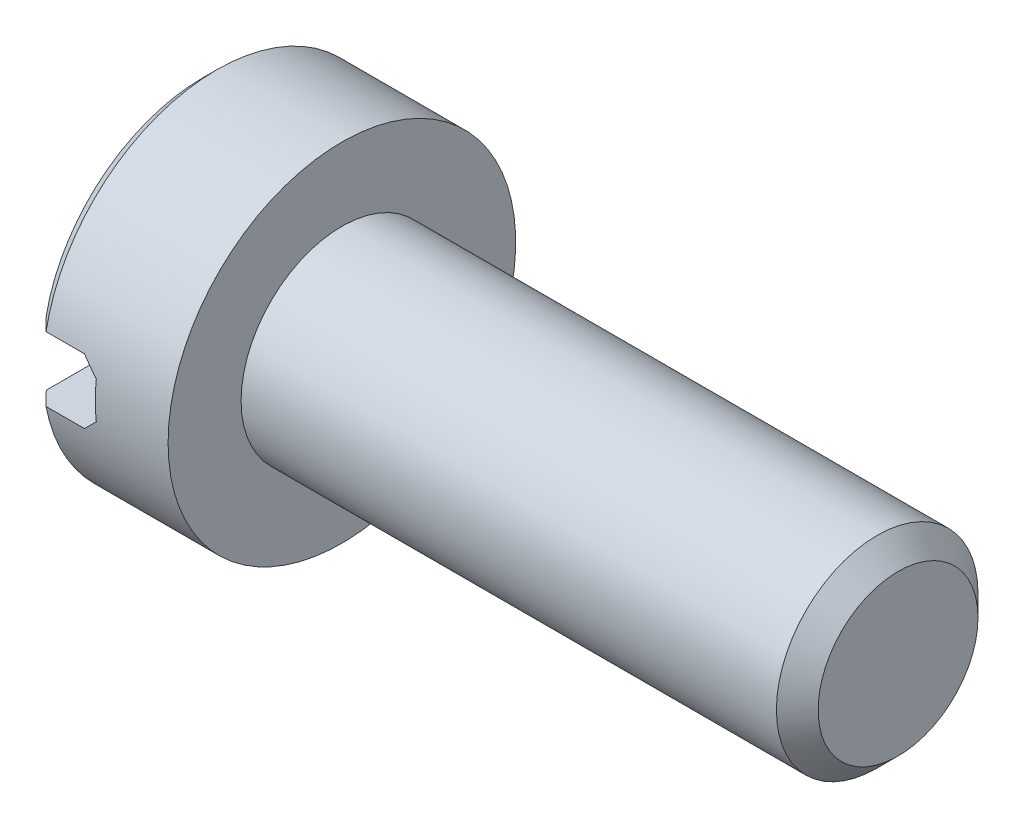
from build123d import *

# Parameters (mm, degrees)
ENL_V_MAT_EXTRU_1_DEPTH = 5
ESQUISSE3_R             = 1.45
EXTRUSION1_DEPTH        = 8
CHANFREIN1_SIZE         = 0.3


with BuildPart() as part:
    # Esquisse1 → Révolution1 (revolve)
    with BuildSketch(Plane.XY, mode=Mode.PRIVATE) as r_volution1_sk:
        Polygon((0, 0), (0, 2.3), (0.2, 2.5), (2, 2.5), (2, 0), align=None)
    revolve(r_volution1_sk.sketch.rotate(Axis((0, 0, 0), (1, 0, 0)), 90), axis=Axis((0, 0, 0), (1, 0, 0)))  # turned: the seam where the file's is

    # Esquisse2 → Enlèv. mat.-Extru.1 (cut, symmetric)
    with BuildSketch(Plane.XY):
        Polygon((0, 0.465549348), (0.753445065, 0.465549348), (0.953445065, 0.265549348), (0.953445065, -0.265549348), (0.753445065, -0.465549348), (0, -0.465549348), align=None)
    extrude(amount=ENL_V_MAT_EXTRU_1_DEPTH, both=True, mode=Mode.SUBTRACT)

    # Esquisse3 → Extrusion1 (add)
    with BuildSketch(Plane(origin=(2, 0, 0), x_dir=(0, 0, -1), z_dir=(1, 0, 0))):
        with Locations(Location((0, 0, 0), (0, 0, 180))):  # turned: the seam where the file's is
            Circle(ESQUISSE3_R)
    extrude(amount=EXTRUSION1_DEPTH)

    # Chanfrein1
    chanfrein1_edges = [part.edges().sort_by_distance(p)[0] for p in [
        (10, 0, -1.45),
    ]]
    chamfer(chanfrein1_edges, length=CHANFREIN1_SIZE)


solid = part.part
